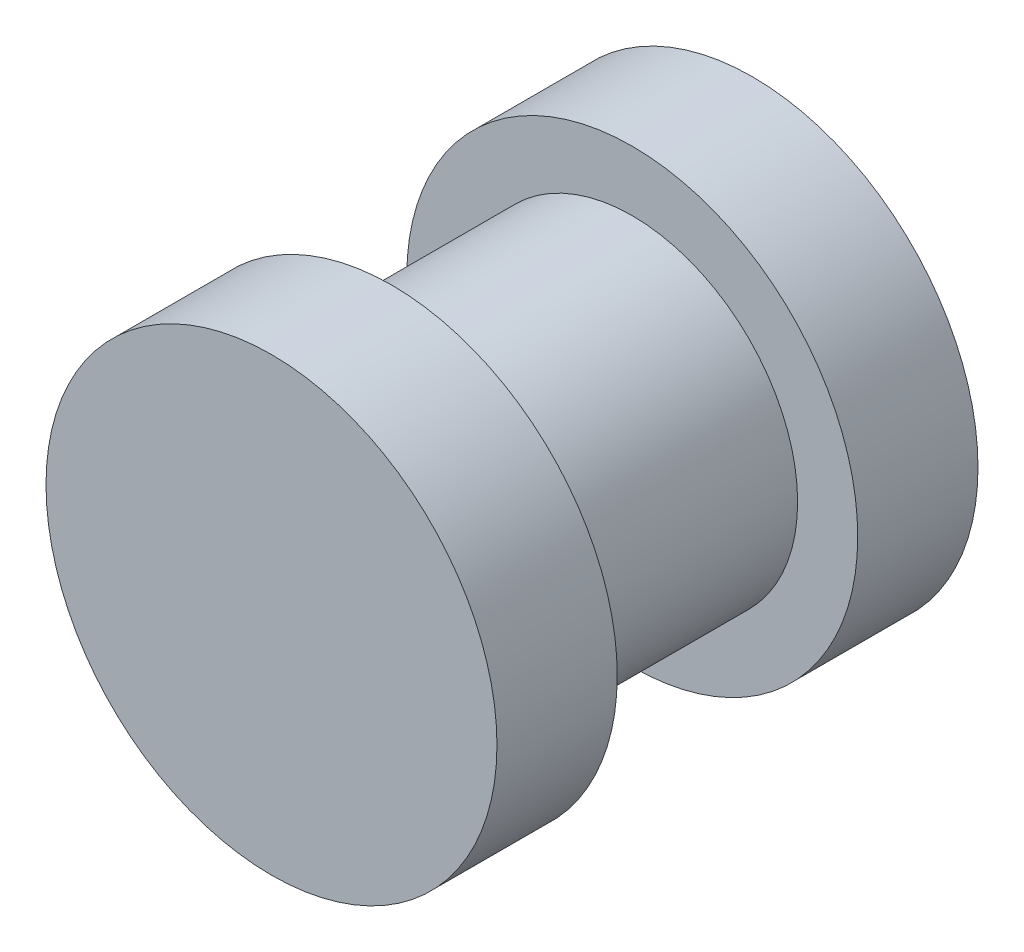
from build123d import *

# Parameters (mm, degrees)
SKETCH1_R           = 4.7625
BOSS_EXTRUDE1_DEPTH = 5.08
SKETCH4_W           = 3.81
SKETCH4_H           = 5.08
CUT_EXTRUDE1_DEPTH  = 3.81
SKETCH8_W           = 5.08
SKETCH8_H           = 2.54


with BuildPart() as part:
    # Sketch1 → Boss-Extrude1 (new body, symmetric)
    with BuildSketch(Plane.XY):
        Circle(SKETCH1_R)
    extrude(amount=BOSS_EXTRUDE1_DEPTH, both=True)

    # Sketch4 → Cut-Extrude1 (cut)
    with BuildSketch(Plane(origin=(0, 0, -5.08), x_dir=(-1, 0, 0), z_dir=(0, 0, -1))):
        Rectangle(SKETCH4_W, SKETCH4_H)
    extrude(amount=-CUT_EXTRUDE1_DEPTH, mode=Mode.SUBTRACT)

    # Sketch8 → Cut-Revolve1 (revolve, cut)
    with BuildSketch(Plane(origin=(0, 0, 0), x_dir=(0, 0, -1), z_dir=(1, 0, 0)), mode=Mode.PRIVATE) as cut_revolve1_sk:
        with Locations((0, 4.7625)):
            Rectangle(SKETCH8_W, SKETCH8_H)
    revolve(cut_revolve1_sk.sketch.rotate(Axis((0, 0, 0), (0, 0, -1)), 90), axis=Axis((0, 0, 0), (0, 0, -1)), mode=Mode.SUBTRACT)  # turned: the seam where the file's is


solid = part.part
